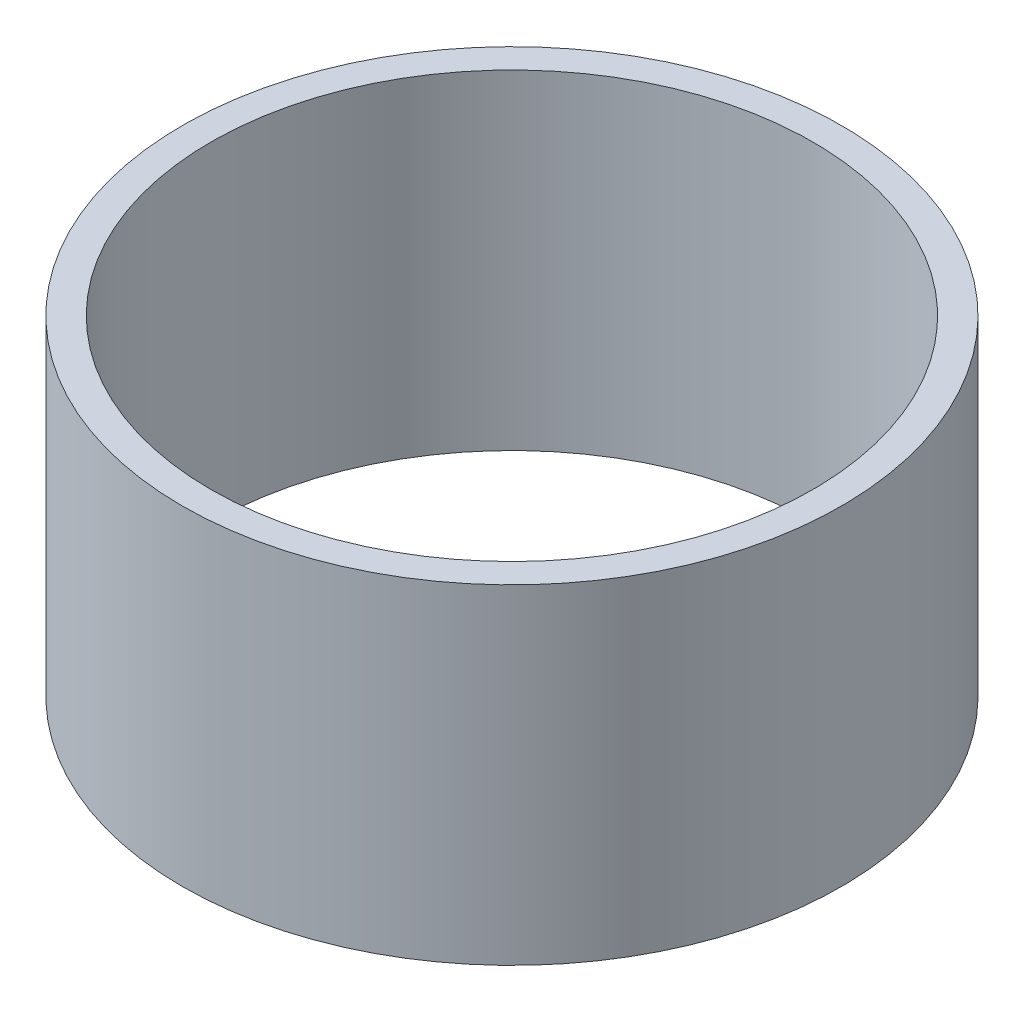
from build123d import *

# Parameters (mm, degrees)
SKETCH1_R               = 19.05
EXTRUDE1_DEPTH          = 9.525
EXTRUDE1_DEPTH_BACK     = 9.525
SKETCH2_R               = 17.399
CUT_EXTRUDE1_DEPTH      = 10.525
CUT_EXTRUDE1_DEPTH_BACK = 10.525


with BuildPart() as part:
    # Sketch1 → Extrude1 (new body, two sides)
    with BuildSketch(Plane(origin=(0, 0, 0), x_dir=(1, 0, 0), z_dir=(0, 1, 0))) as extrude1_sk:
        Circle(SKETCH1_R)
    extrude(amount=EXTRUDE1_DEPTH)
    extrude(extrude1_sk.sketch, amount=-EXTRUDE1_DEPTH_BACK)

    # Sketch2 → Cut-Extrude1 (cut, two sides)
    with BuildSketch(Plane(origin=(0, 0, 0), x_dir=(1, 0, 0), z_dir=(0, 1, 0))) as cut_extrude1_sk:
        Circle(SKETCH2_R)
    extrude(amount=CUT_EXTRUDE1_DEPTH, mode=Mode.SUBTRACT)
    extrude(cut_extrude1_sk.sketch, amount=-CUT_EXTRUDE1_DEPTH_BACK, mode=Mode.SUBTRACT)


solid = part.part
